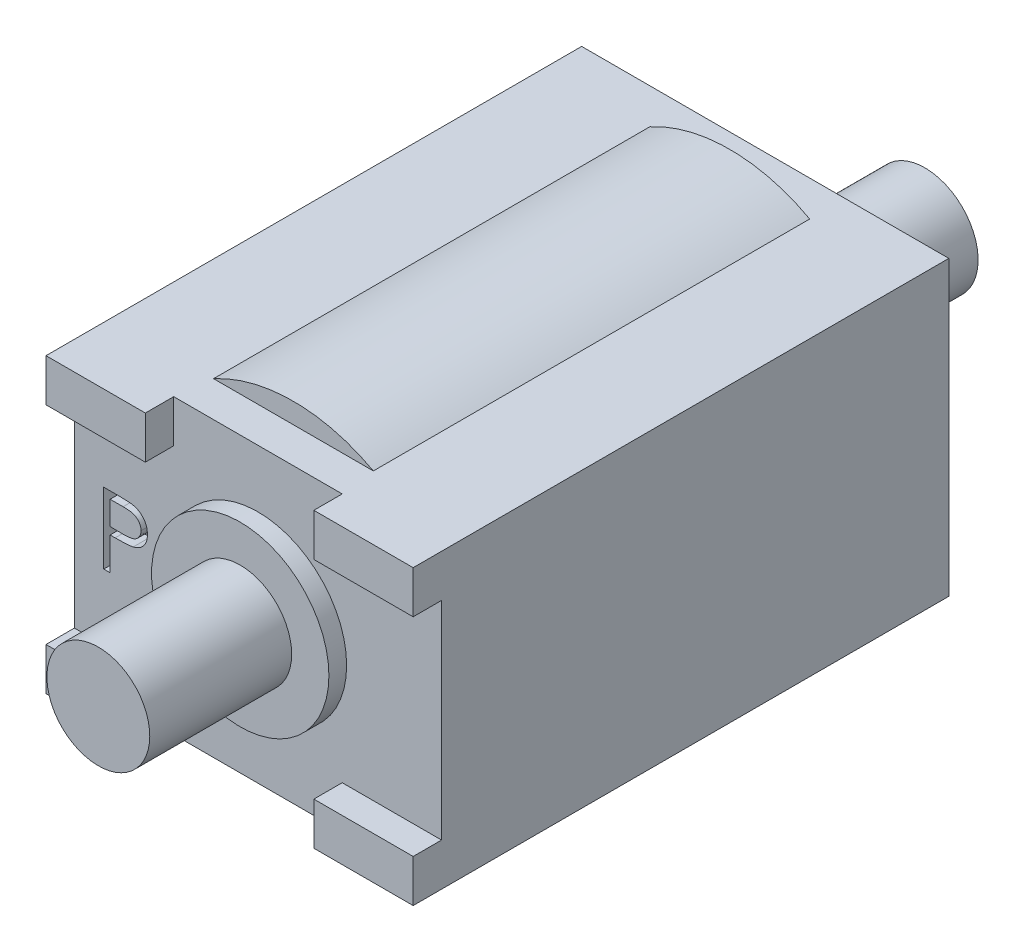
from build123d import *

# Parameters (mm, degrees)
SKETCH1_W           = 10.35
SKETCH1_H           = 8.25
BOSS_EXTRUDE1_DEPTH = 14.3
SKETCH2_R           = 2.5
BOSS_EXTRUDE2_DEPTH = 0.5
SKETCH3_R           = 1.45
BOSS_EXTRUDE3_DEPTH = 4.5
SKETCH4_W           = 2.8
SKETCH4_H           = 1.2
BOSS_EXTRUDE4_DEPTH = 0.8
CUT_EXTRUDE1_DEPTH  = 0.5
SKETCH6_R           = 1.5
BOSS_EXTRUDE5_DEPTH = 4.5
SKETCH7_R           = 1.9
BOSS_EXTRUDE6_DEPTH = 0.3
CUT_EXTRUDE2_DEPTH  = 0.5
BOSS_EXTRUDE7_START = -1
SKETCH9_R           = 4.7
BOSS_EXTRUDE7_DEPTH = 12.3


with BuildPart() as part:
    # Sketch1 → Boss-Extrude1 (new body)
    with BuildSketch(Plane.XY):
        Rectangle(SKETCH1_W, SKETCH1_H)
    extrude(amount=BOSS_EXTRUDE1_DEPTH)

    # Sketch2 → Boss-Extrude2 (add)
    with BuildSketch(Plane.XY.offset(14.3)):
        Circle(SKETCH2_R)
    extrude(amount=BOSS_EXTRUDE2_DEPTH)

    # Sketch3 → Boss-Extrude3 (add)
    with BuildSketch(Plane.XY.offset(14.3)):
        Circle(SKETCH3_R)
    extrude(amount=BOSS_EXTRUDE3_DEPTH)

    # Sketch4 → Boss-Extrude4 (add)
    with BuildSketch(Plane.XY.offset(14.3)):
        with Locations((-3.775, 3.525)):
            Rectangle(SKETCH4_W, SKETCH4_H)
        with Locations((3.775, 3.525)):
            Rectangle(SKETCH4_W, SKETCH4_H)
        with Locations((-3.775, -3.525)):
            Rectangle(SKETCH4_W, SKETCH4_H)
        with Locations((3.775, -3.525)):
            Rectangle(SKETCH4_W, SKETCH4_H)
    extrude(amount=BOSS_EXTRUDE4_DEPTH)

    # Sketch5 → Cut-Extrude1 (cut)
    with BuildSketch(Plane.XY.offset(14.3)):
        with BuildLine():
            Line((-4.347593254, 0.929015226), (-3.95536569, 0.929015226))
            add(Edge.make_bspline(
                [(-3.95536569, 0.929015226), (-3.92838803, 0.928985571), (-3.876697634, 0.928928751), (-3.802574745, 0.927206039), (-3.735254898, 0.924905072), (-3.674883252, 0.921715419), (-3.621274053, 0.917945939), (-3.574669882, 0.912659059), (-3.534704421, 0.90713889), (-3.510757879, 0.901526658), (-3.499836844, 0.898967149)],
                knots=[0, 0, 0, 0, 1.415646017, 2.712440637, 3.8905458, 4.950247383, 5.884950622, 6.709939814, 7.411656543, 8, 8, 8, 8], degree=3))
            add(Edge.make_bspline(
                [(-3.499836844, 0.898967149), (-3.486011968, 0.895183178), (-3.458687981, 0.8877044), (-3.419315956, 0.872725129), (-3.381856616, 0.854963892), (-3.34618144, 0.834721641), (-3.312728821, 0.81112989), (-3.280999654, 0.785144965), (-3.251273951, 0.756166926), (-3.22371887, 0.724520789), (-3.198413272, 0.690737812), (-3.176624882, 0.65431368), (-3.158380752, 0.615861507), (-3.142733168, 0.575408038), (-3.131471194, 0.532613567), (-3.122987251, 0.487775446), (-3.117602321, 0.44089848), (-3.117086572, 0.40886427), (-3.116824024, 0.392556893)],
                knots=[0, 0, 0, 0, 0.999701418, 1.975846123, 2.934577507, 3.890451536, 4.834027766, 5.787354733, 6.749476667, 7.726910423, 8.712836071, 9.690891519, 10.682875813, 11.679750201, 12.712814741, 13.765529915, 14.8625177, 16, 16, 16, 16], degree=3))
            add(Edge.make_bspline(
                [(-3.116824024, 0.392556893), (-3.117064838, 0.376112449), (-3.117536007, 0.343937784), (-3.123191027, 0.296867619), (-3.130808279, 0.251885682), (-3.142520881, 0.20909171), (-3.157861265, 0.168739841), (-3.175856724, 0.130213423), (-3.197561599, 0.094167896), (-3.222501501, 0.0604724), (-3.25024527, 0.029095308), (-3.28067552, 0.000263997), (-3.313669401, -0.025852768), (-3.349122057, -0.049313536), (-3.387379114, -0.069574267), (-3.427860345, -0.087721299), (-3.470917611, -0.102961905), (-3.500713333, -0.110979083), (-3.515862485, -0.115055287)],
                knots=[0, 0, 0, 0, 1.121902311, 2.195077645, 3.232258892, 4.234102512, 5.217864754, 6.176164875, 7.132989551, 8.084763148, 9.034132444, 9.988522005, 10.94243251, 11.903244335, 12.886203696, 13.894208494, 14.929344452, 16, 16, 16, 16], degree=3))
            add(Edge.make_bspline(
                [(-3.515862485, -0.115055287), (-3.52839239, -0.117719847), (-3.555852406, -0.123559387), (-3.601076819, -0.130078505), (-3.653731325, -0.135642848), (-3.713744056, -0.139814927), (-3.781061145, -0.143386566), (-3.855719006, -0.146225477), (-3.937864193, -0.147785393), (-3.995162047, -0.147865846), (-4.025077229, -0.147907851)],
                knots=[0, 0, 0, 0, 0.601384939, 1.31797006, 2.144135048, 3.087295005, 4.142315834, 5.309527816, 6.595305764, 8, 8, 8, 8], degree=3))
            Line((-4.025077229, -0.147907851), (-4.168106075, -0.147907851))
            Line((-4.168106075, -0.147907851), (-4.168106075, -1.070984774))
            Line((-4.168106075, -1.070984774), (-4.347593254, -1.070984774))
            Line((-4.347593254, -1.070984774), (-4.347593254, 0.929015226))
        make_face()
        with BuildLine():
            Line((-4.168106075, 0.723887021), (-4.168106075, 0.057220354))
            Line((-4.168106075, 0.057220354), (-3.817945819, 0.052813303))
            add(Edge.make_bspline(
                [(-3.817945819, 0.052813303), (-3.800848718, 0.052804467), (-3.767843118, 0.052787408), (-3.720165276, 0.055064679), (-3.675931398, 0.057693555), (-3.635277355, 0.061542654), (-3.598184821, 0.066983372), (-3.564591947, 0.072475794), (-3.534759214, 0.080421716), (-3.499845384, 0.091120612), (-3.460940614, 0.109367821), (-3.418616301, 0.135853473), (-3.382747395, 0.169613877), (-3.351708368, 0.207572638), (-3.327076438, 0.249800712), (-3.309044442, 0.294982962), (-3.298449495, 0.342656018), (-3.297028813, 0.375277812), (-3.296311203, 0.391755611)],
                knots=[0, 0, 0, 0, 1.160613943, 2.240541288, 3.23993089, 4.169200891, 5.011653406, 5.7853311, 6.478053781, 7.106038997, 8.262395093, 9.384106736, 10.481365981, 11.59014053, 12.70357646, 13.786202915, 14.881775077, 16, 16, 16, 16], degree=3))
            add(Edge.make_bspline(
                [(-3.296311203, 0.391755611), (-3.297032715, 0.407834761), (-3.298466993, 0.439798122), (-3.309127486, 0.486643129), (-3.327041379, 0.531349245), (-3.351873719, 0.573048151), (-3.382011508, 0.610870325), (-3.417039704, 0.643725826), (-3.456875853, 0.670138228), (-3.493931985, 0.687185817), (-3.526846949, 0.697594546), (-3.55543664, 0.704877312), (-3.587717025, 0.710691944), (-3.623698614, 0.715400231), (-3.663102519, 0.719430781), (-3.70626727, 0.722165625), (-3.753029352, 0.723766457), (-3.785492535, 0.72384586), (-3.802320819, 0.723887021)],
                knots=[0, 0, 0, 0, 1.120700087, 2.227813068, 3.331159281, 4.466773991, 5.599788987, 6.693661531, 7.80175334, 8.91857717, 9.525282508, 10.207424825, 10.974604443, 11.810962634, 12.737642355, 13.736264703, 14.826523623, 16, 16, 16, 16], degree=3))
            Line((-3.802320819, 0.723887021), (-4.168106075, 0.723887021))
        make_face(mode=Mode.SUBTRACT)
    extrude(amount=-CUT_EXTRUDE1_DEPTH, mode=Mode.SUBTRACT)

    # Sketch6 → Boss-Extrude5 (add)
    with BuildSketch(Plane(origin=(0, 0, 0), x_dir=(-1, 0, 0), z_dir=(0, 0, -1))):
        Circle(SKETCH6_R)
    extrude(amount=BOSS_EXTRUDE5_DEPTH)

    # Sketch7 → Boss-Extrude6 (add)
    with BuildSketch(Plane(origin=(0, 0, 0), x_dir=(-1, 0, 0), z_dir=(0, 0, -1))):
        Circle(SKETCH7_R)
    extrude(amount=BOSS_EXTRUDE6_DEPTH)

    # Sketch8 → Cut-Extrude2 (cut)
    with BuildSketch(Plane(origin=(0, 0, 0), x_dir=(-1, 0, 0), z_dir=(0, 0, -1))):
        with BuildLine():
            Line((-4.472736325, 0.956821499), (-4.293249145, 0.956821499))
            Line((-4.293249145, 0.956821499), (-4.293249145, 0.702815089))
            add(Edge.make_bspline(
                [(-4.293249145, 0.702815089), (-4.277086888, 0.725036576), (-4.246118454, 0.767615074), (-4.195338081, 0.823723808), (-4.144608874, 0.871339897), (-4.108075513, 0.896335823), (-4.090524786, 0.908343935)],
                knots=[0, 0, 0, 0, 1.134379233, 2.173579362, 3.122582517, 4, 4, 4, 4], degree=3))
            add(Edge.make_bspline(
                [(-4.090524786, 0.908343935), (-4.066602122, 0.919775572), (-4.019174751, 0.942439123), (-3.944078051, 0.965429728), (-3.867235383, 0.979558357), (-3.815344975, 0.981490571), (-3.789242735, 0.982462525)],
                knots=[0, 0, 0, 0, 1.014936303, 2.012140481, 3.000054389, 4, 4, 4, 4], degree=3))
            add(Edge.make_bspline(
                [(-3.789242735, 0.982462525), (-3.771589594, 0.981865216), (-3.736654977, 0.980683173), (-3.68489264, 0.972991725), (-3.634687719, 0.959696769), (-3.586336845, 0.941178298), (-3.540782171, 0.91875162), (-3.499016916, 0.892437501), (-3.461517368, 0.862896315), (-3.428302482, 0.828794067), (-3.398434467, 0.789173154), (-3.37096084, 0.742965012), (-3.345575005, 0.689132063), (-3.331505685, 0.650065468), (-3.324098504, 0.629497781)],
                knots=[0, 0, 0, 0, 1.009824226, 1.998387844, 2.986035974, 3.974953746, 4.955485308, 5.885931332, 6.793869504, 7.679848016, 8.601185859, 9.625726857, 10.749998409, 12, 12, 12, 12], degree=3))
            add(Edge.make_bspline(
                [(-3.324098504, 0.629497781), (-3.316263503, 0.643626021), (-3.300845322, 0.671428412), (-3.274956387, 0.710775991), (-3.247831932, 0.747579872), (-3.219240793, 0.781869257), (-3.189283886, 0.813474817), (-3.157820229, 0.842501047), (-3.125028925, 0.869072597), (-3.079433359, 0.900114403), (-3.020111869, 0.933086506), (-2.945318661, 0.961674189), (-2.867518563, 0.979340548), (-2.81470845, 0.981414989), (-2.788040812, 0.982462525)],
                knots=[0, 0, 0, 0, 0.86119277, 1.694706429, 2.50939023, 3.298075842, 4.073795165, 4.829715201, 5.57930267, 6.321991688, 7.768977793, 9.186738141, 10.579381044, 12, 12, 12, 12], degree=3))
            add(Edge.make_bspline(
                [(-2.788040812, 0.982462525), (-2.763537119, 0.981538399), (-2.715581012, 0.979729794), (-2.645765432, 0.965527809), (-2.580655829, 0.941140582), (-2.520383214, 0.907864218), (-2.466006178, 0.866047542), (-2.418739715, 0.816293921), (-2.378870936, 0.758955279), (-2.352825999, 0.705017), (-2.335160134, 0.65739681), (-2.324268, 0.616821786), (-2.314645317, 0.572163756), (-2.306656034, 0.523369321), (-2.300816862, 0.470266116), (-2.296490738, 0.412941044), (-2.293562696, 0.351349552), (-2.293355798, 0.30885498), (-2.293249145, 0.286949704)],
                knots=[0, 0, 0, 0, 1.209669288, 2.367440248, 3.500751976, 4.631527125, 5.755587489, 6.87532382, 8.007944318, 9.190864318, 9.82315674, 10.514484317, 11.263564316, 12.079023757, 12.955305781, 13.901327259, 14.918167583, 16, 16, 16, 16], degree=3))
            Line((-2.293249145, 0.286949704), (-2.293249145, -0.504716962))
            Line((-2.293249145, -0.504716962), (-2.472736325, -0.504716962))
            Line((-2.472736325, -0.504716962), (-2.472736325, 0.287750986))
            add(Edge.make_bspline(
                [(-2.472736325, 0.287750986), (-2.472780829, 0.306448457), (-2.47286636, 0.342382152), (-2.474405578, 0.393954982), (-2.477305758, 0.440965472), (-2.48069698, 0.483349522), (-2.485407728, 0.521205973), (-2.491491118, 0.554458783), (-2.497935506, 0.583369532), (-2.508641787, 0.615418703), (-2.525754868, 0.650773109), (-2.551821999, 0.688900866), (-2.58466206, 0.722089895), (-2.622582149, 0.750900362), (-2.665752689, 0.774325299), (-2.713332531, 0.791054448), (-2.765026275, 0.801410378), (-2.800810725, 0.802442387), (-2.819290812, 0.802975345)],
                knots=[0, 0, 0, 0, 1.253487763, 2.409012846, 3.458416907, 4.410876679, 5.259312806, 6.014470957, 6.676830364, 7.243083969, 8.276244668, 9.299465089, 10.325150304, 11.392391894, 12.482080715, 13.603491619, 14.762376348, 16, 16, 16, 16], degree=3))
            add(Edge.make_bspline(
                [(-2.819290812, 0.802975345), (-2.841959357, 0.802166112), (-2.886761021, 0.800566761), (-2.952158441, 0.784238833), (-3.014999022, 0.759621547), (-3.07340767, 0.723945858), (-3.127137836, 0.681198221), (-3.173366166, 0.630369881), (-3.211555986, 0.572867065), (-3.237415401, 0.519640378), (-3.253752145, 0.471829267), (-3.264538954, 0.430059341), (-3.272929463, 0.382584159), (-3.280798337, 0.329722736), (-3.285934182, 0.271111204), (-3.290601823, 0.207020689), (-3.292785173, 0.137258427), (-3.293090578, 0.088900319), (-3.293249145, 0.063792653)],
                knots=[0, 0, 0, 0, 1.090531906, 2.155305635, 3.229839962, 4.33261226, 5.44038871, 6.529323825, 7.629011124, 8.757537029, 9.370236727, 10.061839251, 10.834451254, 11.692844982, 12.636905849, 13.66920014, 14.789842145, 16, 16, 16, 16], degree=3))
            Line((-3.293249145, 0.063792653), (-3.293249145, -0.504716962))
            Line((-3.293249145, -0.504716962), (-3.472736325, -0.504716962))
            Line((-3.472736325, -0.504716962), (-3.472736325, 0.23847214))
            add(Edge.make_bspline(
                [(-3.472736325, 0.23847214), (-3.472781714, 0.259439751), (-3.472869038, 0.299779326), (-3.474398362, 0.357627141), (-3.477305003, 0.410244901), (-3.480665316, 0.457571452), (-3.485499704, 0.499520782), (-3.490990997, 0.536317787), (-3.497475917, 0.567870216), (-3.508212994, 0.602477865), (-3.524621262, 0.640604106), (-3.551014554, 0.681256118), (-3.583933171, 0.716837888), (-3.622545101, 0.747214316), (-3.665976919, 0.772323734), (-3.713967434, 0.790415021), (-3.766084527, 0.800943186), (-3.802014644, 0.802285184), (-3.820492735, 0.802975345)],
                knots=[0, 0, 0, 0, 1.320475261, 2.540461679, 3.643808994, 4.639130445, 5.527981419, 6.302341397, 6.981980563, 7.553956391, 8.582137848, 9.585246428, 10.591171744, 11.620968678, 12.668337649, 13.738356861, 14.836885341, 16, 16, 16, 16], degree=3))
            add(Edge.make_bspline(
                [(-3.820492735, 0.802975345), (-3.842216284, 0.802100797), (-3.885510547, 0.800357852), (-3.949111672, 0.784669696), (-4.010532063, 0.760095939), (-4.068791891, 0.726004614), (-4.122319976, 0.683776569), (-4.169181843, 0.634110914), (-4.208577571, 0.577625752), (-4.234710037, 0.524960314), (-4.251566308, 0.478347014), (-4.262763642, 0.438717901), (-4.272386286, 0.394717759), (-4.279537155, 0.346210839), (-4.28644025, 0.293513071), (-4.289771855, 0.236361934), (-4.293012748, 0.174806455), (-4.293168413, 0.132307858), (-4.293249145, 0.110267012)],
                knots=[0, 0, 0, 0, 1.098833095, 2.189935336, 3.297829714, 4.440610912, 5.596351641, 6.740013378, 7.886572111, 9.072425424, 9.705826452, 10.395263256, 11.156850408, 11.985370555, 12.878090359, 13.847760091, 14.883794034, 16, 16, 16, 16], degree=3))
            Line((-4.293249145, 0.110267012), (-4.293249145, -0.504716962))
            Line((-4.293249145, -0.504716962), (-4.472736325, -0.504716962))
            Line((-4.472736325, -0.504716962), (-4.472736325, 0.956821499))
        make_face()
    extrude(amount=-CUT_EXTRUDE2_DEPTH, mode=Mode.SUBTRACT)

    # Sketch9 → Boss-Extrude7 (add)
    with BuildSketch(Plane(origin=(0, 0, 0), x_dir=(-1, 0, 0), z_dir=(0, 0, -1)).offset(BOSS_EXTRUDE7_START)):
        Circle(SKETCH9_R)
    extrude(amount=-BOSS_EXTRUDE7_DEPTH)


solid = part.part
